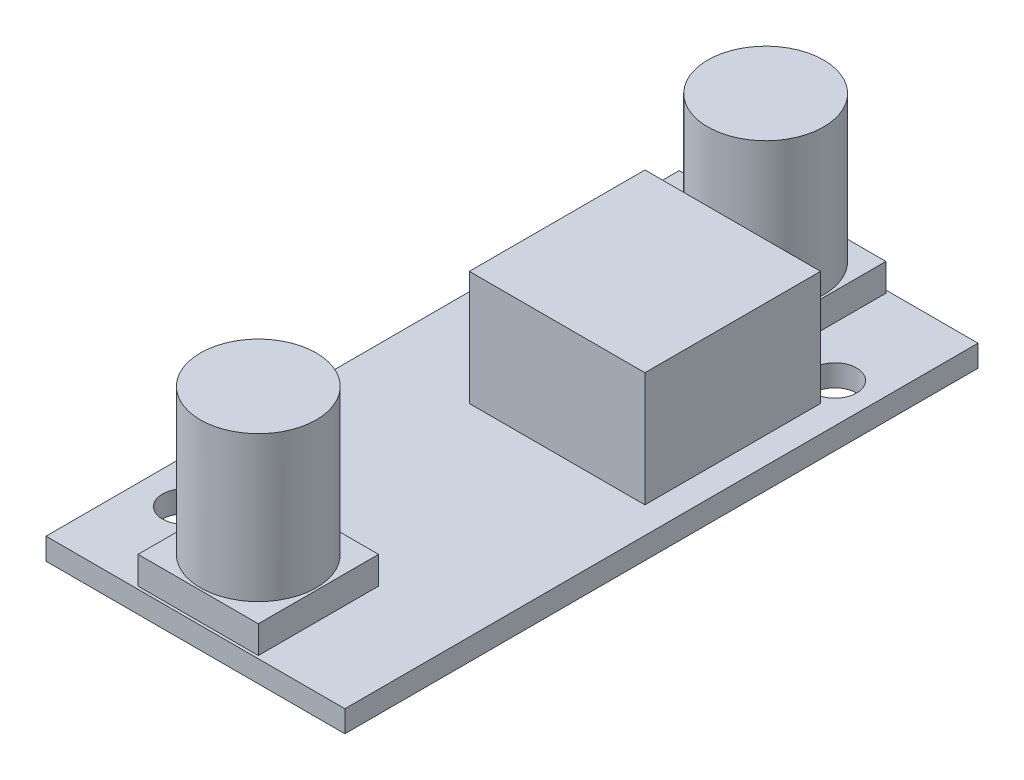
from build123d import *

# Parameters (mm, degrees)
SKETCH1_W           = 20.63
SKETCH1_H           = 43.7
BOSS_EXTRUDE1_DEPTH = 1.5
SKETCH2_R           = 1.5
CUT_EXTRUDE1_DEPTH  = 1.5
BOSS_EXTRUDE2_DEPTH = 1.9
SKETCH4_R           = 4
BOSS_EXTRUDE3_DEPTH = 10.04
SKETCH5_W           = 12.12
SKETCH5_H           = 12.12
BOSS_EXTRUDE4_DEPTH = 7.9


with BuildPart() as part:
    # Sketch1 → Boss-Extrude1 (new body)
    with BuildSketch(Plane(origin=(0, 0, 0), x_dir=(1, 0, 0), z_dir=(0, 1, 0))):
        Rectangle(SKETCH1_W, SKETCH1_H)
    extrude(amount=BOSS_EXTRUDE1_DEPTH)

    # Sketch2 → Cut-Extrude1 (cut)
    with BuildSketch(Plane(origin=(0, 1.5, 0), x_dir=(1, 0, 0), z_dir=(0, 1, 0))):
        with Locations((7.605, 14.68)):
            Circle(SKETCH2_R)
        with Locations((-7.315, -15.31)):
            Circle(SKETCH2_R)
    extrude(amount=-CUT_EXTRUDE1_DEPTH, mode=Mode.SUBTRACT)

    # Sketch3 → Boss-Extrude2 (add)
    with BuildSketch(Plane(origin=(0, 1.5, 0), x_dir=(1, 0, 0), z_dir=(0, 1, 0))):
        Polygon((0, -21.66), (-4.15, -21.66), (-4.15, -13.36), (4.15, -13.36), (4.15, -21.66), align=None)
    boss_extrude2 = extrude(amount=BOSS_EXTRUDE2_DEPTH)

    # Sketch4 → Boss-Extrude3 (add)
    with BuildSketch(Plane(origin=(0, 3.4, 0), x_dir=(1, 0, 0), z_dir=(0, 1, 0))):
        with Locations((0, -17.51)):
            Circle(SKETCH4_R)
    boss_extrude3 = extrude(amount=BOSS_EXTRUDE3_DEPTH)

    # Mirror1: Boss-Extrude2, Boss-Extrude3 across plane
    add(boss_extrude2.mirror(Plane.XY))
    add(boss_extrude3.mirror(Plane.XY))

    # Sketch5 → Boss-Extrude4 (add)
    with BuildSketch(Plane(origin=(0, 1.5, 0), x_dir=(1, 0, 0), z_dir=(0, 1, 0))):
        with Locations((2.425, 6.75)):
            Rectangle(SKETCH5_W, SKETCH5_H)
    extrude(amount=BOSS_EXTRUDE4_DEPTH)


solid = part.part
